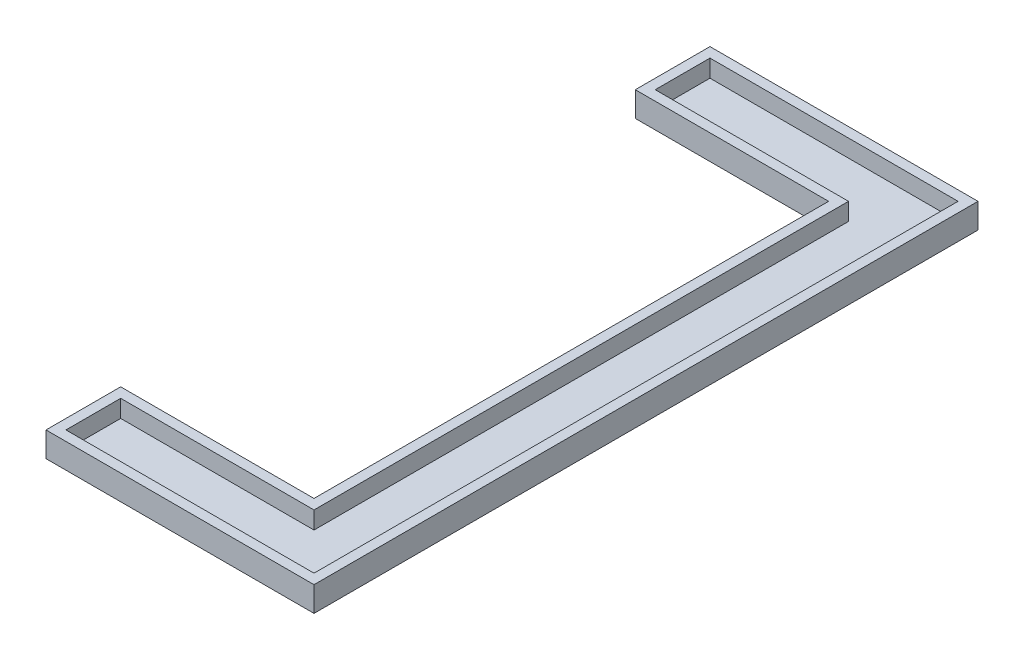
from build123d import *

# Parameters (mm, degrees)
BOSS_EXTRUDE1_DEPTH = 4
CUT_EXTRUDE1_DEPTH  = 2.8


with BuildPart() as part:
    # Sketch1 → Boss-Extrude1 (new body)
    with BuildSketch(Plane(origin=(0, 0, 0), x_dir=(1, 0, 0), z_dir=(0, 1, 0))):
        Polygon((0, 106.68), (43.06, 106.68), (43.06, 0), (0, 0), (0, 12), (31.06, 12), (31.06, 94.68), (0, 94.68), align=None)
    extrude(amount=BOSS_EXTRUDE1_DEPTH)

    # Sketch2 → Cut-Extrude1 (cut)
    with BuildSketch(Plane(origin=(0, 4, 0), x_dir=(1, 0, 0), z_dir=(0, 1, 0))):
        Polygon((1.6, 105.08), (1.6, 96.28), (32.66, 96.28), (32.66, 10.4), (1.6, 10.4), (1.6, 1.6), (41.46, 1.6), (41.46, 105.08), align=None)
    extrude(amount=-CUT_EXTRUDE1_DEPTH, mode=Mode.SUBTRACT)


solid = part.part
